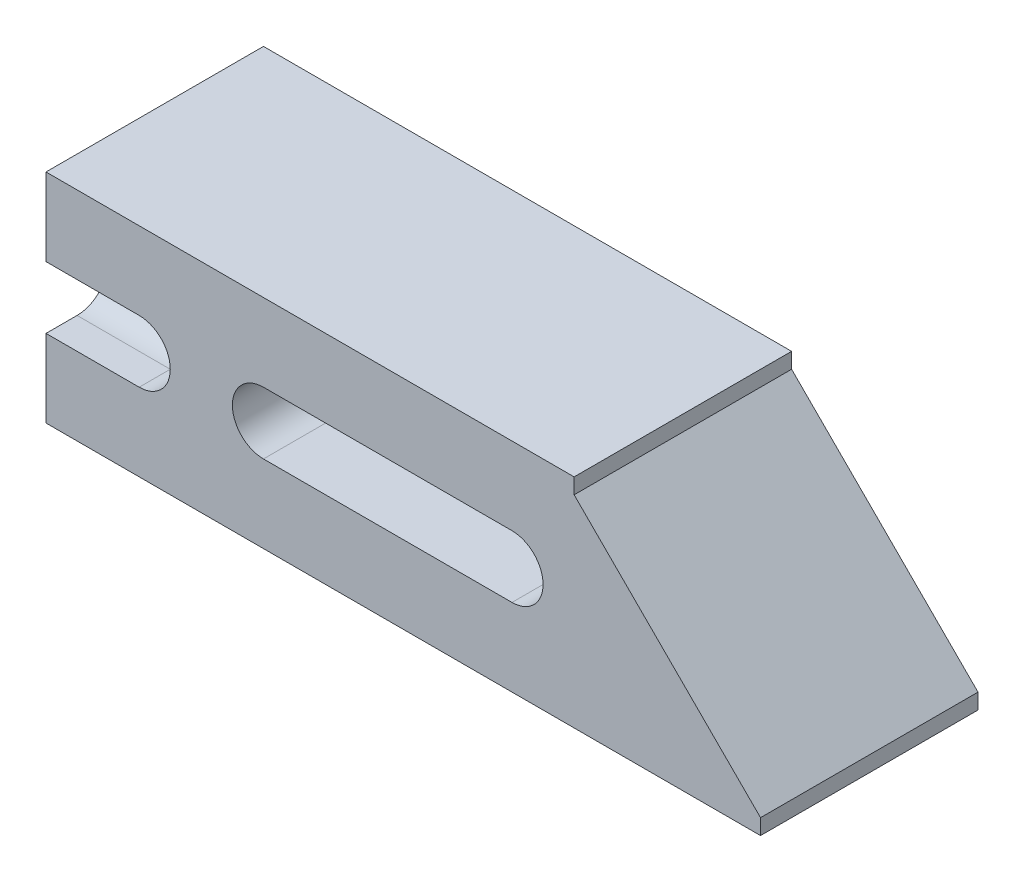
from build123d import *

# Parameters (mm, degrees)
BOSS_EXTRUDE1_DEPTH = 22.225
SKETCH8_R           = 3.175
CUT_EXTRUDE7_DEPTH  = 29.21
CUT_EXTRUDE8_REACH  = 75.025


with BuildPart() as part:
    # Sketch1 → Boss-Extrude1 (new body)
    with BuildSketch(Plane.XY):
        Polygon((0, 0), (0, 22.225), (53.975, 22.225), (53.975, 20.6375), (73.025, 1.5875), (73.025, 0), align=None)
    extrude(amount=BOSS_EXTRUDE1_DEPTH)

    # Sketch8 → Cut-Extrude7 (cut)
    with BuildSketch(Plane.XY.offset(22.225)):
        with Locations((9.525, 11.1125)):
            Circle(SKETCH8_R)
        with BuildLine():
            Line((22.225, 14.2875), (47.625, 14.2875))
            ThreePointArc((47.625, 14.2875), (50.8, 11.1125), (47.625, 7.9375))
            Line((47.625, 7.9375), (22.225, 7.9375))
            ThreePointArc((22.225, 7.9375), (19.05, 11.1125), (22.225, 14.2875))
        make_face()
    extrude(amount=-CUT_EXTRUDE7_DEPTH, mode=Mode.SUBTRACT)

    # Sketch10 → Cut-Extrude8 (cut, up to next)
    with BuildSketch(Plane.ZY, mode=Mode.PRIVATE) as cut_extrude8_sk1:
        with BuildLine():
            Line((3.175, 14.2875), (0, 14.2875))
            Line((0, 14.2875), (0, 7.9375))
            Line((0, 7.9375), (3.175, 7.9375))
            ThreePointArc((3.175, 7.9375), (6.35, 11.1125), (3.175, 14.2875))
        make_face()
    cut_extrude8_tool1 = extrude(cut_extrude8_sk1.sketch, amount=-CUT_EXTRUDE8_REACH, mode=Mode.PRIVATE) & part.part
    add(cut_extrude8_tool1.solids().sort_by_distance((0, 11.1125, 2.878614))[0], mode=Mode.SUBTRACT)
    # Sketch10 → Cut-Extrude8 (cut, up to next)
    with BuildSketch(Plane.ZY, mode=Mode.PRIVATE) as cut_extrude8_sk2:
        with BuildLine():
            Line((19.05, 7.9375), (22.225, 7.9375))
            Line((22.225, 7.9375), (22.225, 14.2875))
            Line((22.225, 14.2875), (19.05, 14.2875))
            ThreePointArc((19.05, 14.2875), (15.875, 11.1125), (19.05, 7.9375))
        make_face()
    cut_extrude8_tool2 = extrude(cut_extrude8_sk2.sketch, amount=-CUT_EXTRUDE8_REACH, mode=Mode.PRIVATE) & part.part
    add(cut_extrude8_tool2.solids().sort_by_distance((0, 11.1125, 19.346386))[0], mode=Mode.SUBTRACT)


solid = part.part
